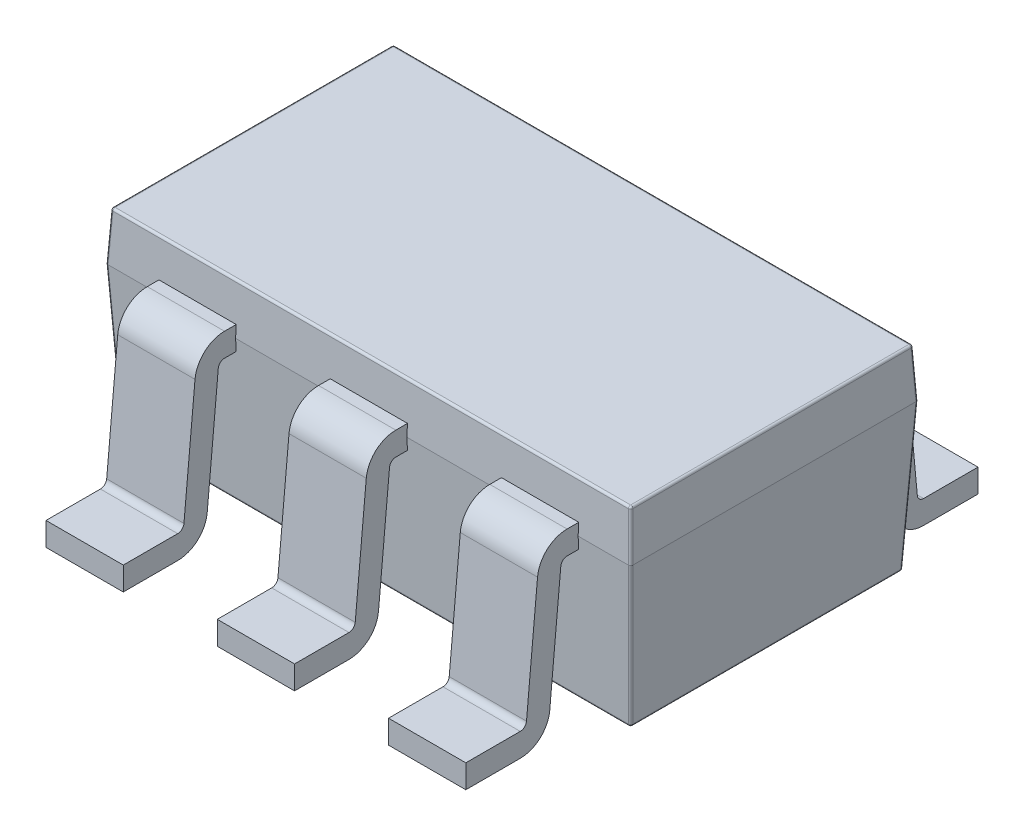
from build123d import *

# Parameters (mm, degrees)
SKETCH1_W                      = 2.92
SKETCH1_H                      = 1.6
EXTRUDE1_DEPTH                 = 0.27
EXTRUDE1_TAPER                 = 3
EXTRUDE1_OTHER_WAY_DEPTH       = 0.82
EXTRUDE1_OTHER_WAY_TAPER       = 3
FILLET1_R                      = 0.0125
SKETCH4_W                      = 0.43
SKETCH4_H                      = 0.13
PADR_O_LINEAR1_COUNT           = 3
PADR_O_LINEAR1_PITCH           = 0.953
PADR_O_LINEAR2_COPY_1_SKETCH_W = 0.43
PADR_O_LINEAR2_COPY_1_SKETCH_H = 0.13
PADR_O_LINEAR2_COPY_2_SKETCH_W = 0.43
PADR_O_LINEAR2_COPY_2_SKETCH_H = 0.13


with BuildPart() as part:
    # Sketch1 → Extrude1 (new body)
    with BuildSketch(Plane(origin=(0, 0, 0), x_dir=(1, 0, 0), z_dir=(0, 1, 0))):
        Rectangle(SKETCH1_W, SKETCH1_H)
    extrude(amount=EXTRUDE1_DEPTH, taper=EXTRUDE1_TAPER)

    # Sketch1 → Extrude1 other way (add)
    with BuildSketch(Plane(origin=(0, 0, 0), x_dir=(1, 0, 0), z_dir=(0, 1, 0))):
        Rectangle(SKETCH1_W, SKETCH1_H)
    extrude(amount=-EXTRUDE1_OTHER_WAY_DEPTH, taper=EXTRUDE1_OTHER_WAY_TAPER)

    # Fillet1
    fillet1_edges = [part.edges().sort_by_distance(p)[0] for p in [
        (1.417025621, -0.82, 0),
        (-1.45292495, 0.135, -0.79292495),
        (0, -0.82, -0.757025621),
        (-1.45292495, 0.135, 0.79292495),
        (1.45292495, 0.135, 0.79292495),
        (1.45292495, 0.135, -0.79292495),
        (-1.4458499, 0.27, 0),
        (0, 0.27, 0.7858499),
        (1.4458499, 0.27, 0),
        (0, 0.27, -0.7858499),
        (-1.417025621, -0.82, 0),
        (0, -0.82, 0.757025621),
        (-1.43851281, -0.41, -0.77851281),
        (1.43851281, -0.41, -0.77851281),
        (1.43851281, -0.41, 0.77851281),
        (-1.43851281, -0.41, 0.77851281),
    ]]
    fillet(fillet1_edges, radius=FILLET1_R)

    # Sweep2: sweep along a path in Sketch3
    with BuildLine(Plane(origin=(0.953, 0, 0), x_dir=(0, 0, -1), z_dir=(1, 0, 0))) as sweep2_path:
        Line((-0.75, 0), (-0.861557331, 0))
        ThreePointArc((-0.861557331, 0), (-0.928924331, -0.02609677), (-0.961130108, -0.090766253))
        Line((-0.961130108, -0.090766253), (-1.022655872, -0.754233747))
        ThreePointArc((-1.022655872, -0.754233747), (-1.054861649, -0.81890323), (-1.122228649, -0.845))
        Line((-1.122228649, -0.845), (-1.425, -0.845))
    # Sketch4 → Sweep2 (sweep)
    with BuildSketch(Plane.XY.offset(1.425)):
        with Locations((0.953, -0.845)):
            Rectangle(SKETCH4_W, SKETCH4_H)
    sweep2 = sweep(path=sweep2_path.line)

    # Espelhar2: Sweep2 across plane
    add(sweep2.mirror(Plane.XY))

    # Padrão linear1: Sweep2 ×3
    with Locations(*[(-i * PADR_O_LINEAR1_PITCH, 0, 0) for i in range(1, PADR_O_LINEAR1_COUNT)]):
        add(sweep2)

    # Padrão linear2 copy 1: sweep along a path in Padrão linear2 copy 1 path
    with BuildLine(Plane(origin=(-0.953, 0, 0), x_dir=(0, 0, 1), z_dir=(1, 0, 0))) as padr_o_linear2_copy_1_path:
        Line((-0.75, 0), (-0.861557331, 0))
        ThreePointArc((-0.861557331, 0), (-0.928924331, 0.02609677), (-0.961130108, 0.090766253))
        Line((-0.961130108, 0.090766253), (-1.022655872, 0.754233747))
        ThreePointArc((-1.022655872, 0.754233747), (-1.054861649, 0.81890323), (-1.122228649, 0.845))
        Line((-1.122228649, 0.845), (-1.425, 0.845))
    # Padrão linear2 copy 1 sketch → Padrão linear2 copy 1 (sweep)
    with BuildSketch(Plane(origin=(-1.906, 0, -1.425), x_dir=(1, 0, 0), z_dir=(0, 0, -1))):
        with Locations((0.953, 0.845)):
            Rectangle(PADR_O_LINEAR2_COPY_1_SKETCH_W, PADR_O_LINEAR2_COPY_1_SKETCH_H)
    sweep(path=padr_o_linear2_copy_1_path.line)

    # Padrão linear2 copy 2: sweep along a path in Padrão linear2 copy 2 path
    with BuildLine(Plane(origin=(-0.953, 0, 0), x_dir=(0, 0, -1), z_dir=(1, 0, 0))) as padr_o_linear2_copy_2_path:
        Line((-0.75, 0), (-0.861557331, 0))
        ThreePointArc((-0.861557331, 0), (-0.928924331, -0.02609677), (-0.961130108, -0.090766253))
        Line((-0.961130108, -0.090766253), (-1.022655872, -0.754233747))
        ThreePointArc((-1.022655872, -0.754233747), (-1.054861649, -0.81890323), (-1.122228649, -0.845))
        Line((-1.122228649, -0.845), (-1.425, -0.845))
    # Padrão linear2 copy 2 sketch → Padrão linear2 copy 2 (sweep)
    with BuildSketch(Plane(origin=(-1.906, 0, 1.425), x_dir=(1, 0, 0), z_dir=(0, 0, 1))):
        with Locations((0.953, -0.845)):
            Rectangle(PADR_O_LINEAR2_COPY_2_SKETCH_W, PADR_O_LINEAR2_COPY_2_SKETCH_H)
    sweep(path=padr_o_linear2_copy_2_path.line)


solid = part.part
